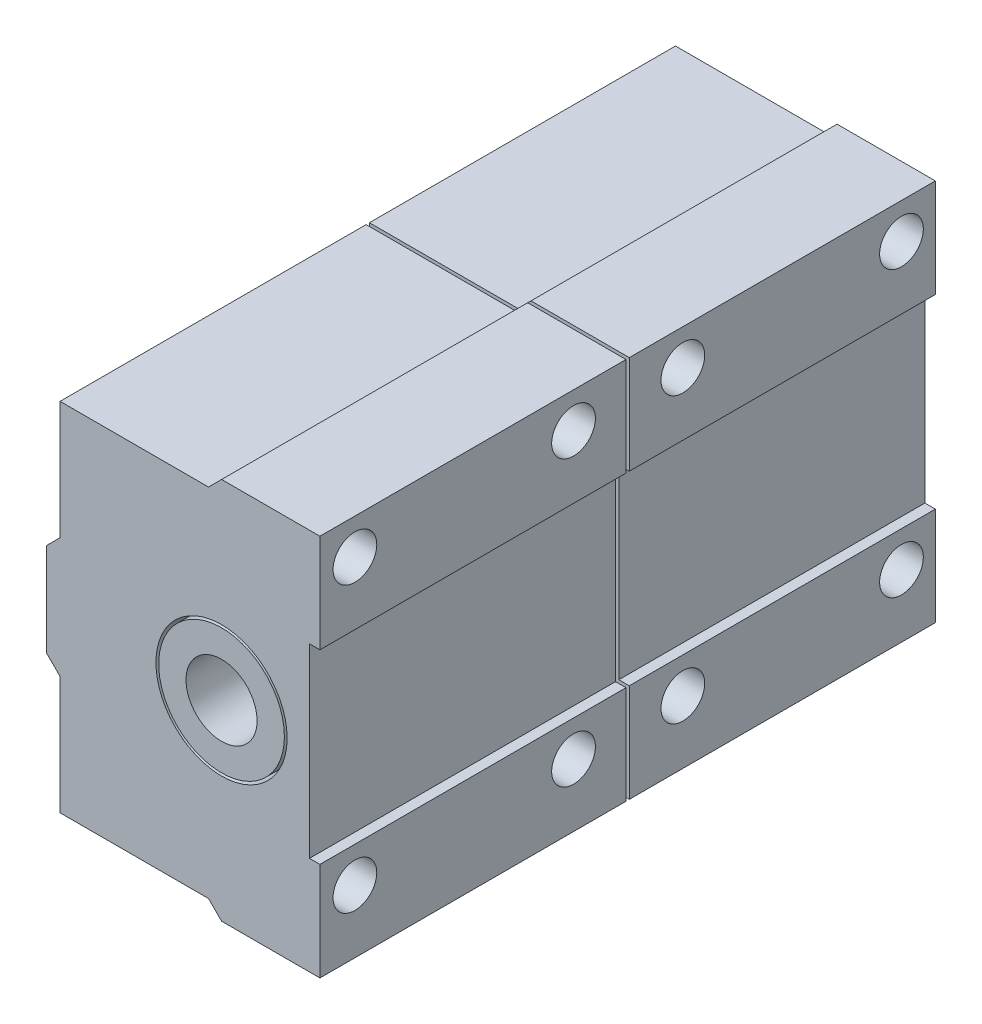
from build123d import *

# Parameters (mm, degrees)
SKETCH1_W             = 28
SKETCH1_H             = 35
BOSS_EXTRUDE1_DEPTH   = 25
BOSS_EXTRUDE1_2_DEPTH = 25
SKETCH4_R             = 2
CUT_EXTRUDE1_DEPTH    = 10
SKETCH5_R             = 1
CUT_EXTRUDE2_DEPTH    = 3
SKETCH6_R             = 6
CUT_EXTRUDE3_DEPTH    = 82
SKETCH7_W             = 0.957204126
SKETCH7_H             = 17
CUT_EXTRUDE4_DEPTH    = 82
CUT_EXTRUDE5_DEPTH    = 82
SKETCH9_R             = 5.75
SKETCH9_R_2           = 3.25
BOSS_EXTRUDE2_DEPTH   = 56.3


with BuildPart() as part:
    # Sketch1 → Boss-Extrude1 (new body)
    with BuildSketch(Plane.ZY.offset(-76.969208633)):
        with Locations((212.2, 7.55)):
            Rectangle(SKETCH1_W, SKETCH1_H)
    extrude(amount=BOSS_EXTRUDE1_DEPTH)


with BuildPart() as body_2:
    # Sketch1 → Boss-Extrude1 2 (new body)
    with BuildSketch(Plane.ZY.offset(-76.969208633)):
        with Locations((183.9, 7.55)):
            Rectangle(SKETCH1_W, SKETCH1_H)
    extrude(amount=BOSS_EXTRUDE1_2_DEPTH)


with BuildPart() as cut_extrude1_tool:
    # Sketch4 → Cut-Extrude1 (new body)
    with BuildSketch(Plane(origin=(76.969208633, 0, 0), x_dir=(0, 0, -1), z_dir=(1, 0, 0))):
        with Locations((-193, 21.8)):
            Circle(SKETCH4_R)
        with Locations((-173, 21.8)):
            Circle(SKETCH4_R)
        with Locations((-173, -4.2)):
            Circle(SKETCH4_R)
        with Locations((-193, -4.2)):
            Circle(SKETCH4_R)
        with Locations((-223, -4.2)):
            Circle(SKETCH4_R)
        with Locations((-203, -4.2)):
            Circle(SKETCH4_R)
        with Locations((-203, 21.8)):
            Circle(SKETCH4_R)
        with Locations((-223, 21.8)):
            Circle(SKETCH4_R)
    extrude(amount=-CUT_EXTRUDE1_DEPTH)


with BuildPart() as part_1:
    add(part.part)

    # Cut-Extrude1: cut by cut_extrude1_tool
    add(cut_extrude1_tool.part, mode=Mode.SUBTRACT)


with BuildPart() as body_2_1:
    add(body_2.part)

    # Cut-Extrude1: cut by cut_extrude1_tool
    add(cut_extrude1_tool.part, mode=Mode.SUBTRACT)


with BuildPart() as cut_extrude2_tool:
    # Sketch5 → Cut-Extrude2 (new body)
    with BuildSketch(Plane.ZY.offset(-51.969208633)):
        with Locations((223, 21.8)):
            Circle(SKETCH5_R)
        with Locations((223, -4.2)):
            Circle(SKETCH5_R)
        with Locations((203, -4.2)):
            Circle(SKETCH5_R)
        with Locations((203, 21.8)):
            Circle(SKETCH5_R)
        with Locations((193, 21.8)):
            Circle(SKETCH5_R)
        with Locations((193, -4.2)):
            Circle(SKETCH5_R)
        with Locations((173, -4.2)):
            Circle(SKETCH5_R)
        with Locations((173, 21.8)):
            Circle(SKETCH5_R)
    extrude(amount=-CUT_EXTRUDE2_DEPTH)


with BuildPart() as part_2:
    add(part_1.part)

    # Cut-Extrude2: cut by cut_extrude2_tool
    add(cut_extrude2_tool.part, mode=Mode.SUBTRACT)


with BuildPart() as body_2_2:
    add(body_2_1.part)

    # Cut-Extrude2: cut by cut_extrude2_tool
    add(cut_extrude2_tool.part, mode=Mode.SUBTRACT)


with BuildPart() as cut_extrude3_tool:
    # Sketch6 → Cut-Extrude3 (new body)
    with BuildSketch(Plane.XY.offset(226.2)):
        with Locations((67.969208633, 7.55)):
            Circle(SKETCH6_R)
    extrude(amount=-CUT_EXTRUDE3_DEPTH)


with BuildPart() as part_3:
    add(part_2.part)

    # Cut-Extrude3: cut by cut_extrude3_tool
    add(cut_extrude3_tool.part, mode=Mode.SUBTRACT)


with BuildPart() as body_2_3:
    add(body_2_2.part)

    # Cut-Extrude3: cut by cut_extrude3_tool
    add(cut_extrude3_tool.part, mode=Mode.SUBTRACT)


with BuildPart() as cut_extrude4_tool:
    # Sketch7 → Cut-Extrude4 (new body)
    with BuildSketch(Plane.XY.offset(226.2)):
        with Locations((76.49060657, 7.55)):
            Rectangle(SKETCH7_W, SKETCH7_H)
    extrude(amount=-CUT_EXTRUDE4_DEPTH)


with BuildPart() as part_4:
    add(part_3.part)

    # Cut-Extrude4: cut by cut_extrude4_tool
    add(cut_extrude4_tool.part, mode=Mode.SUBTRACT)


with BuildPart() as body_2_4:
    add(body_2_3.part)

    # Cut-Extrude4: cut by cut_extrude4_tool
    add(cut_extrude4_tool.part, mode=Mode.SUBTRACT)


with BuildPart() as cut_extrude5_tool:
    # Sketch8 → Cut-Extrude5 (new body)
    with BuildSketch(Plane.XY.offset(226.2)):
        Polygon((67.976384402, 25.05), (66.776384402, 23.85), (53.195802703, 23.85), (53.195802703, 13.044895511), (51.969208633, 11.818301441), (51.969208633, 25.05), align=None)
        Polygon((53.195802703, 2.055104489), (51.969208633, 3.281698559), (51.969208633, -9.95), (67.976384402, -9.95), (66.776384402, -8.75), (53.195802703, -8.75), align=None)
    extrude(amount=-CUT_EXTRUDE5_DEPTH)


with BuildPart() as part_5:
    add(part_4.part)

    # Cut-Extrude5: cut by cut_extrude5_tool
    add(cut_extrude5_tool.part, mode=Mode.SUBTRACT)


with BuildPart() as body_2_5:
    add(body_2_4.part)

    # Cut-Extrude5: cut by cut_extrude5_tool
    add(cut_extrude5_tool.part, mode=Mode.SUBTRACT)


with BuildPart() as body_3:
    # Sketch9 → Boss-Extrude2 (new body)
    with BuildSketch(Plane.XY.offset(226.2)):
        with Locations((67.969208633, 7.55)):
            Circle(SKETCH9_R)
        with Locations((67.969208633, 7.55)):
            Circle(SKETCH9_R_2, mode=Mode.SUBTRACT)
    extrude(amount=-BOSS_EXTRUDE2_DEPTH)


solid = Compound([part_5.part, body_2_5.part, body_3.part])
